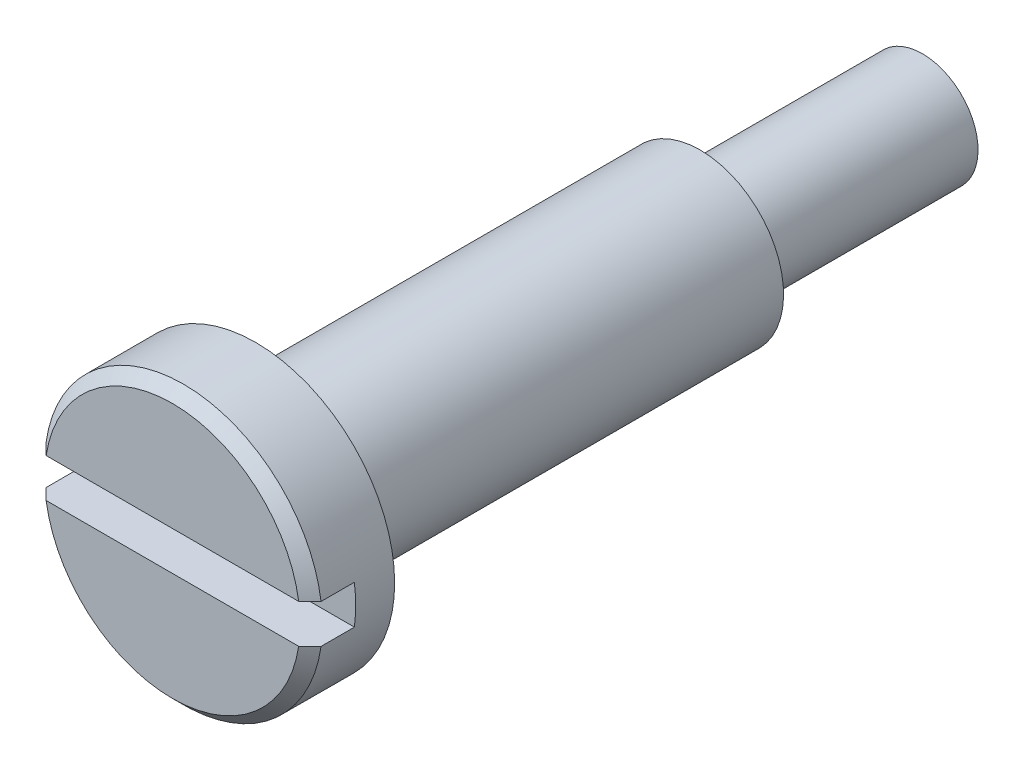
from build123d import *

# Parameters (mm, degrees)
SKETCH_2_W               = 1.6
SKETCH_2_H               = 0.7
CUT_EXTRUDE_1_DEPTH      = 3.5
CUT_EXTRUDE_1_DEPTH_BACK = 3.5
CHAMFER_1_SIZE           = 0.2


with BuildPart() as part:
    # 草图1 → 旋转1 (revolve)
    with BuildSketch(Plane(origin=(0, 0, 0), x_dir=(0, 0, -1), z_dir=(1, 0, 0))):
        Polygon((0, 0), (0, 2.5), (1.5, 2.5), (1.5, 1.5), (9.5, 1.5), (9.5, 0.7), (9.8, 0.7), (9.8, 1), (13.5, 1), (13.5, 0), align=None)
    revolve(axis=Axis((0, 0, -13.5), (0, 0, 1)))

    # 草图2 → 切除-拉伸1 (cut, two sides)
    with BuildSketch(Plane(origin=(0, 0, 0), x_dir=(0, 0, -1), z_dir=(1, 0, 0))) as cut_extrude_1_sk:
        Rectangle(SKETCH_2_W, SKETCH_2_H)
    extrude(amount=CUT_EXTRUDE_1_DEPTH, mode=Mode.SUBTRACT)
    extrude(cut_extrude_1_sk.sketch, amount=-CUT_EXTRUDE_1_DEPTH_BACK, mode=Mode.SUBTRACT)

    # 倒角1
    chamfer_1_edges = [part.edges().sort_by_distance(p)[0] for p in [
        (0, -2.5, 0),
        (-1.639359631, 1.887458609, 0),
    ]]
    chamfer(chamfer_1_edges, length=CHAMFER_1_SIZE)


solid = part.part
